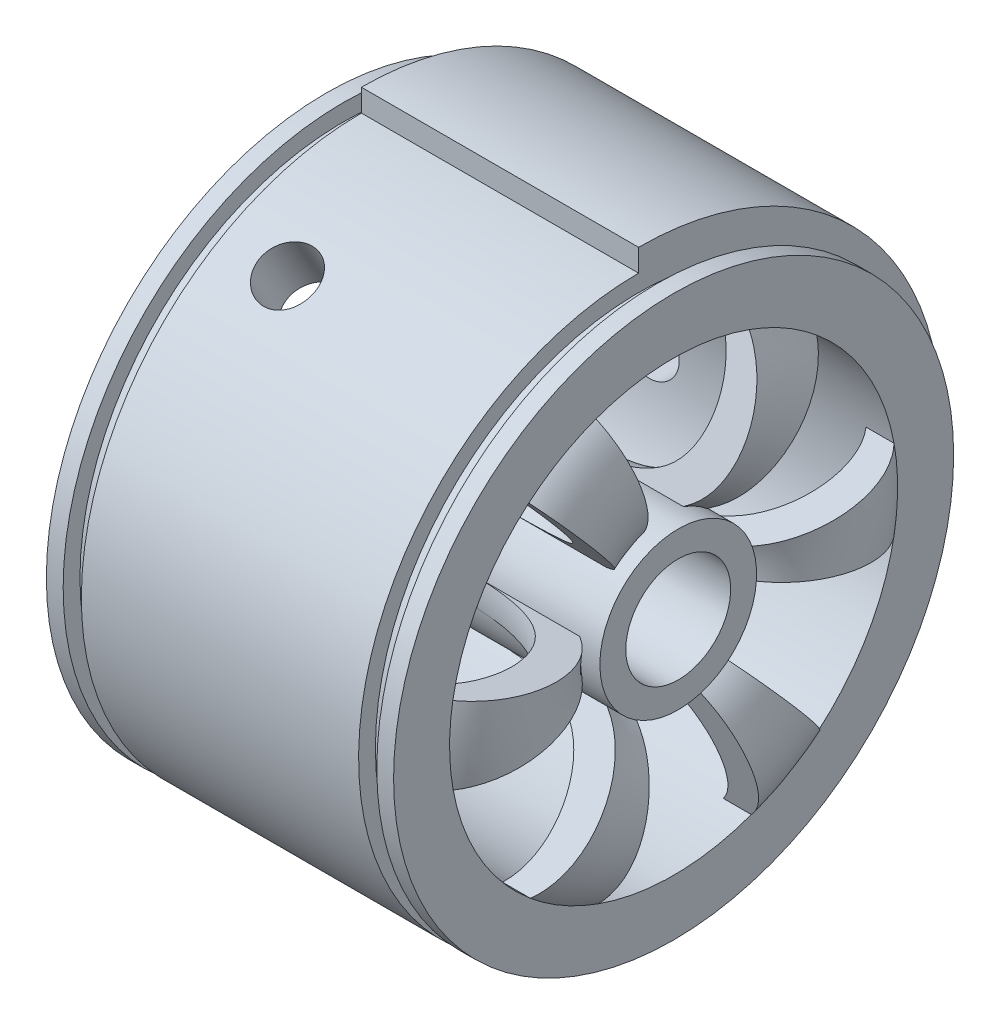
from build123d import *

# Parameters (mm, degrees)
SKETCH2_R           = 13.994994
SKETCH2_R_2         = 9.362874
BOSS_EXTRUDE1_DEPTH = 22
CUT_EXTRUDE1_REACH  = 98.842
CIRPATTERN1_COUNT   = 6
SKETCH5_R           = 5
CUT_EXTRUDE2_DEPTH  = 79.974092
CIRPATTERN2_COUNT   = 3
SKETCH6_W           = 49.5
SKETCH6_H           = 4
REVOLVE2_ANGLE      = 80
SKETCH8_R           = 9.362874
BOSS_EXTRUDE2_DEPTH = 10


with BuildPart() as part:
    # Sketch1 → Revolve1 (revolve)
    with BuildSketch(Plane.XY, mode=Mode.PRIVATE) as revolve1_sk:
        with BuildLine():
            Line((28, 50), (28, 47))
            Line((28, 47), (24.75, 47))
            Line((24.75, 47), (24.75, 50))
            Line((24.75, 50), (-24.75, 50))
            Line((-24.75, 50), (-24.75, 47))
            Line((-24.75, 47), (-28, 47))
            Line((-28, 47), (-28, 50))
            Line((-28, 50), (-31, 50))
            Line((-31, 50), (-31, 40))
            Line((-31, 40), (26, 40))
            add(Edge.make_bspline(
                [(26, 40), (30.773626, 34.243877), (29.458402, 17.515745), (16.165909, 14.338363), (10.585807, 14.024235), (9.824917, 13.994994)],
                knots=[0, 0, 0, 0, 0.466678, 0.747183, 0.791718, 0.791718, 0.791718, 0.791718], degree=3))
            Line((9.824917, 13.994994), (9.824917, 9.362874))
            add(Edge.make_bspline(
                [(31, 40), (36.846282, 33.806819), (36.013625, 16.052231), (20.480531, 10.25448), (12.499278, 9.514566), (9.824917, 9.362874)],
                knots=[0, 0, 0, 0, 0.436989, 0.685709, 0.818804, 0.818804, 0.818804, 0.818804], degree=3))
            Line((31, 40), (31, 50))
            Line((31, 50), (28, 50))
        make_face()
    revolve(revolve1_sk.sketch.rotate(Axis((0, 0, 0), (1, 0, 0)), 90), axis=Axis((0, 0, 0), (1, 0, 0)))

    # Sketch2 → Boss-Extrude1 (add)
    with BuildSketch(Plane.ZY.offset(-9.824917)):
        Circle(SKETCH2_R)
        Circle(SKETCH2_R_2, mode=Mode.SUBTRACT)
    extrude(amount=-BOSS_EXTRUDE1_DEPTH)

    # Sketch4 → Cut-Extrude1 (cut, up to next)
    with BuildSketch(Plane.ZY.offset(31), mode=Mode.PRIVATE) as cut_extrude1_sk1:
        with BuildLine():
            Line((-4.72289, 13.173996), (-13.498797, 37.653452))
            ThreePointArc((-13.498797, 37.653452), (0.193519, 39.999532), (13.862494, 37.521077))
            Line((13.862494, 37.521077), (4.850138, 13.127682))
            ThreePointArc((4.850138, 13.127682), (0.067708, 13.994831), (-4.72289, 13.173996))
        make_face()
    cut_extrude1_tool1 = extrude(cut_extrude1_sk1.sketch, amount=-CUT_EXTRUDE1_REACH, mode=Mode.PRIVATE) & part.part
    cut_extrude1 = cut_extrude1_tool1.solids().sort_by_distance((-31, 28.497517, 0.137872))[0]
    add(cut_extrude1, mode=Mode.SUBTRACT)

    # CirPattern1: Cut-Extrude1 ×6 about axis
    cirpattern1_axis = Axis((0, 0, 0), (1, 0, 0))
    for i in range(1, CIRPATTERN1_COUNT):
        add(cut_extrude1.rotate(cirpattern1_axis, i * 360 / CIRPATTERN1_COUNT), mode=Mode.SUBTRACT)

    # Sketch5 → Cut-Extrude2 (cut, through all)
    with BuildSketch(Plane.XY):
        with Locations((-13, 0)):
            Circle(SKETCH5_R)
    cut_extrude2 = extrude(amount=-CUT_EXTRUDE2_DEPTH, mode=Mode.SUBTRACT)

    # CirPattern2: Cut-Extrude2 ×3 about axis
    cirpattern2_axis = Axis((0, 0, 0), (-1, 0, 0))
    for i in range(1, CIRPATTERN2_COUNT):
        add(cut_extrude2.rotate(cirpattern2_axis, i * 360 / CIRPATTERN2_COUNT), mode=Mode.SUBTRACT)

    # Sketch6 → Revolve2 (revolve)
    with BuildSketch(Plane.XY):
        with Locations((0, 52)):
            Rectangle(SKETCH6_W, SKETCH6_H)
    revolve(axis=Axis((0, 0, 0), (-1, 0, 0)), revolution_arc=REVOLVE2_ANGLE)

    # Sketch8 → Boss-Extrude2 (add)
    with BuildSketch(Plane.ZY.offset(-9.824917)):
        with BuildLine():
            ThreePointArc((4.850138, 13.127682), (0.067708, 13.994831), (-4.72289, 13.173996))
            ThreePointArc((-4.72289, 13.173996), (-6.938779, 12.153733), (-8.943837, 10.764184))
            ThreePointArc((-8.943837, 10.764184), (-12.086025, 7.056052), (-13.77046, 2.496856))
            ThreePointArc((-13.77046, 2.496856), (-13.994831, 0.067708), (-13.793975, -2.363498))
            ThreePointArc((-13.793975, -2.363498), (-12.153733, -6.938779), (-9.047571, -10.677141))
            ThreePointArc((-9.047571, -10.677141), (-7.056052, -12.086025), (-4.850138, -13.127682))
            ThreePointArc((-4.850138, -13.127682), (-0.067708, -13.994831), (4.72289, -13.173996))
            ThreePointArc((4.72289, -13.173996), (6.938779, -12.153733), (8.943837, -10.764184))
            ThreePointArc((8.943837, -10.764184), (12.086025, -7.056052), (13.77046, -2.496856))
            ThreePointArc((13.77046, -2.496856), (13.994831, -0.067708), (13.793975, 2.363498))
            ThreePointArc((13.793975, 2.363498), (12.153733, 6.938779), (9.047571, 10.677141))
            ThreePointArc((9.047571, 10.677141), (7.056052, 12.086025), (4.850138, 13.127682))
        make_face()
        Circle(SKETCH8_R, mode=Mode.SUBTRACT)
    extrude(amount=BOSS_EXTRUDE2_DEPTH)


solid = part.part
